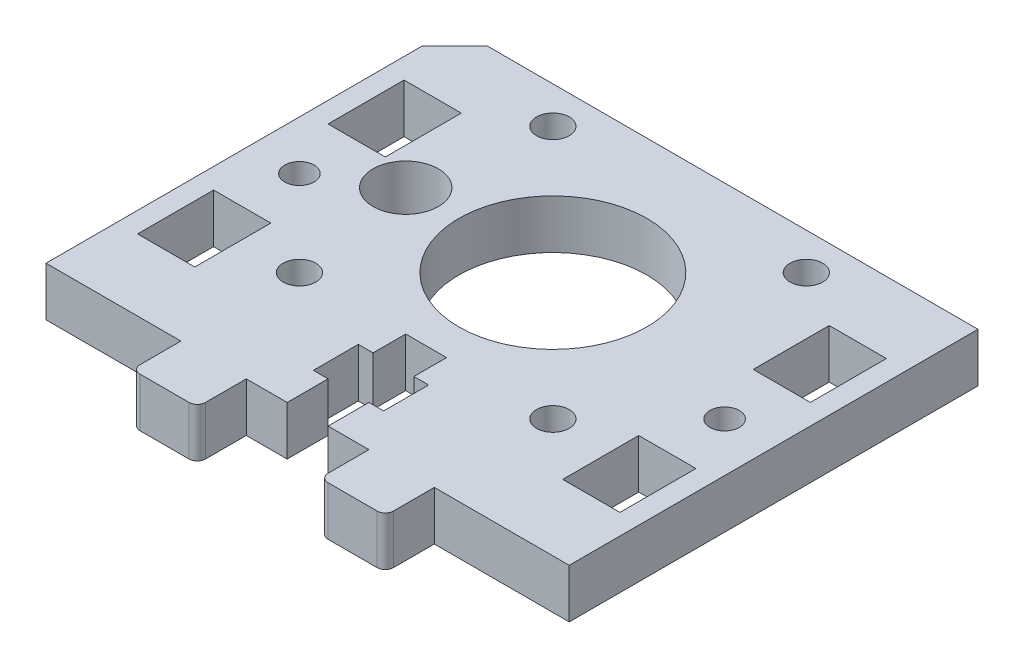
from build123d import *

# Parameters (mm, degrees)
ESQUISSE2_W             = 64
ESQUISSE2_H             = 50
ESQUISSE2_R             = 11.5
ESQUISSE2_R_2           = 4
ESQUISSE2_R_3           = 2
ESQUISSE2_R_4           = 1.8
ESQUISSE2_W_2           = 7
ESQUISSE2_H_2           = 9.3
BOSS_EXTRU_1_DEPTH      = 3
BOSS_EXTRU_2_DEPTH      = 6
ENL_V_MAT_EXTRU_1_DEPTH = 6
CHANFREIN1_SIZE         = 4


with BuildPart() as part:
    # Esquisse2 → Boss.-Extru.1 (new, symmetric)
    with BuildSketch(Plane(origin=(0, 0, 0), x_dir=(1, 0, 0), z_dir=(0, 1, 0))):
        Rectangle(ESQUISSE2_W, ESQUISSE2_H)
        with Locations((0, 5)):
            Circle(ESQUISSE2_R, mode=Mode.SUBTRACT)
        with Locations((-18, 5)):
            Circle(ESQUISSE2_R_2, mode=Mode.SUBTRACT)
        with Locations((15.5, -10.5)):
            Circle(ESQUISSE2_R_3, mode=Mode.SUBTRACT)
        with Locations((15.5, 20.5)):
            Circle(ESQUISSE2_R_3, mode=Mode.SUBTRACT)
        with Locations((-15.5, 20.5)):
            Circle(ESQUISSE2_R_3, mode=Mode.SUBTRACT)
        with Locations((-15.5, -10.5)):
            Circle(ESQUISSE2_R_3, mode=Mode.SUBTRACT)
        with Locations((26, 0)):
            Circle(ESQUISSE2_R_4, mode=Mode.SUBTRACT)
        with Locations((-26, 0)):
            Circle(ESQUISSE2_R_4, mode=Mode.SUBTRACT)
        with Locations((26, 11.65)):
            Rectangle(ESQUISSE2_W_2, ESQUISSE2_H_2, mode=Mode.SUBTRACT)
        with Locations((26, -11.65)):
            Rectangle(ESQUISSE2_W_2, ESQUISSE2_H_2, mode=Mode.SUBTRACT)
        with Locations((-26, -11.65)):
            Rectangle(ESQUISSE2_W_2, ESQUISSE2_H_2, mode=Mode.SUBTRACT)
        with Locations((-26, 11.65)):
            Rectangle(ESQUISSE2_W_2, ESQUISSE2_H_2, mode=Mode.SUBTRACT)
    extrude(amount=BOSS_EXTRU_1_DEPTH, both=True)

    # Esquisse3 → Boss.-Extru.2 (add)
    with BuildSketch(Plane(origin=(0, 3, 0), x_dir=(1, 0, 0), z_dir=(0, 1, 0))):
        with BuildLine():
            Line((-7.5, -30), (-7.5, -25))
            Line((-7.5, -25), (-15.5, -25))
            Line((-15.5, -25), (-15.5, -30))
            ThreePointArc((-15.5, -30), (-15.207106781, -30.707106781), (-14.5, -31))
            Line((-14.5, -31), (-8.5, -31))
            ThreePointArc((-8.5, -31), (-7.792893219, -30.707106781), (-7.5, -30))
        make_face()
        with BuildLine():
            Line((15.5, -30), (15.5, -25))
            Line((15.5, -25), (7.5, -25))
            Line((7.5, -25), (7.5, -30))
            ThreePointArc((7.5, -30), (7.792893219, -30.707106781), (8.5, -31))
            Line((8.5, -31), (14.5, -31))
            ThreePointArc((14.5, -31), (15.207106781, -30.707106781), (15.5, -30))
        make_face()
    extrude(amount=-BOSS_EXTRU_2_DEPTH)

    # Esquisse3_3 → Enl_v. mat.-Extru.1 (cut)
    with BuildSketch(Plane(origin=(0, 3, 0), x_dir=(1, 0, 0), z_dir=(0, 1, 0))):
        Polygon((-2.5, -25), (2.5, -25), (2.5, -20), (4.3, -20), (4.3, -14.5), (2.5, -14.5), (2.5, -10.5), (-2.5, -10.5), (-2.5, -14.5), (-4.3, -14.5), (-4.3, -20), (-2.5, -20), align=None)
    extrude(amount=-ENL_V_MAT_EXTRU_1_DEPTH, mode=Mode.SUBTRACT)

    # Chanfrein1
    chanfrein1_edges = [part.edges().sort_by_distance(p)[0] for p in [
        (-32, 0, -25),
    ]]
    chamfer(chanfrein1_edges, length=CHANFREIN1_SIZE)


solid = part.part
